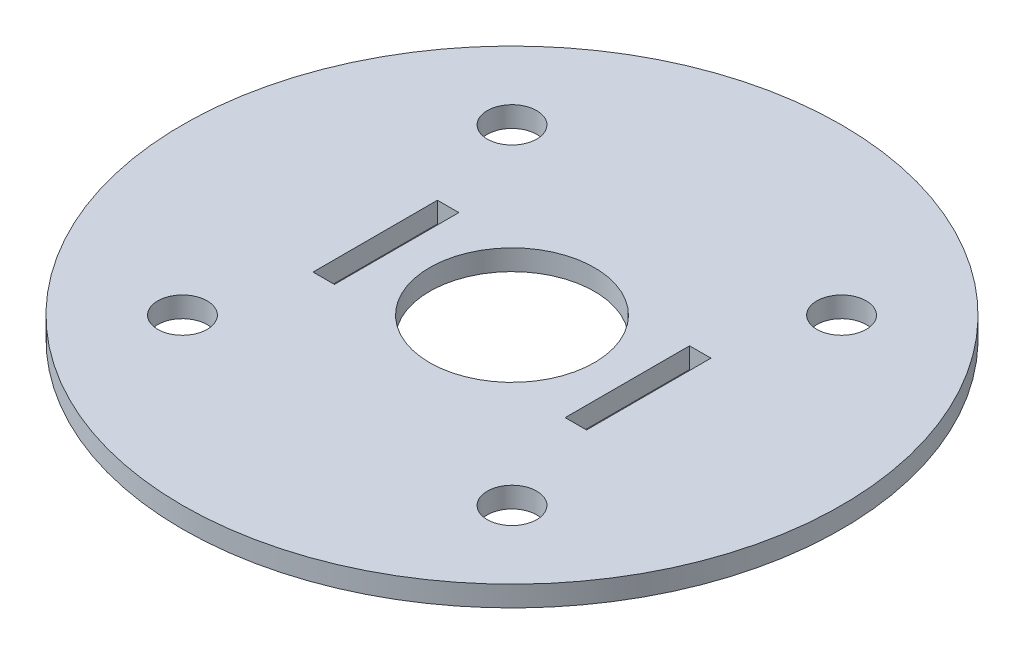
from build123d import *

# Parameters (mm, degrees)
SKETCH1_R           = 50.8
SKETCH1_R_2         = 3.81
SKETCH1_R_3         = 12.7
SKETCH1_W           = 3.302
SKETCH1_H           = 19.177
BOSS_EXTRUDE1_DEPTH = 3.175


with BuildPart() as part:
    # Sketch1 → Boss-Extrude1 (new body)
    with BuildSketch(Plane(origin=(0, 0, 0), x_dir=(1, 0, 0), z_dir=(0, 1, 0))):
        Circle(SKETCH1_R)
        with Locations((-25.4, 25.4)):
            Circle(SKETCH1_R_2, mode=Mode.SUBTRACT)
        with Locations((-25.4, -25.4)):
            Circle(SKETCH1_R_2, mode=Mode.SUBTRACT)
        with Locations((25.4, -25.4)):
            Circle(SKETCH1_R_2, mode=Mode.SUBTRACT)
        with Locations((25.4, 25.4)):
            Circle(SKETCH1_R_2, mode=Mode.SUBTRACT)
        Circle(SKETCH1_R_3, mode=Mode.SUBTRACT)
        with Locations((19.431, 0)):
            Rectangle(SKETCH1_W, SKETCH1_H, mode=Mode.SUBTRACT)
        with Locations((-19.431, 0)):
            Rectangle(SKETCH1_W, SKETCH1_H, mode=Mode.SUBTRACT)
    extrude(amount=BOSS_EXTRUDE1_DEPTH)


solid = part.part
